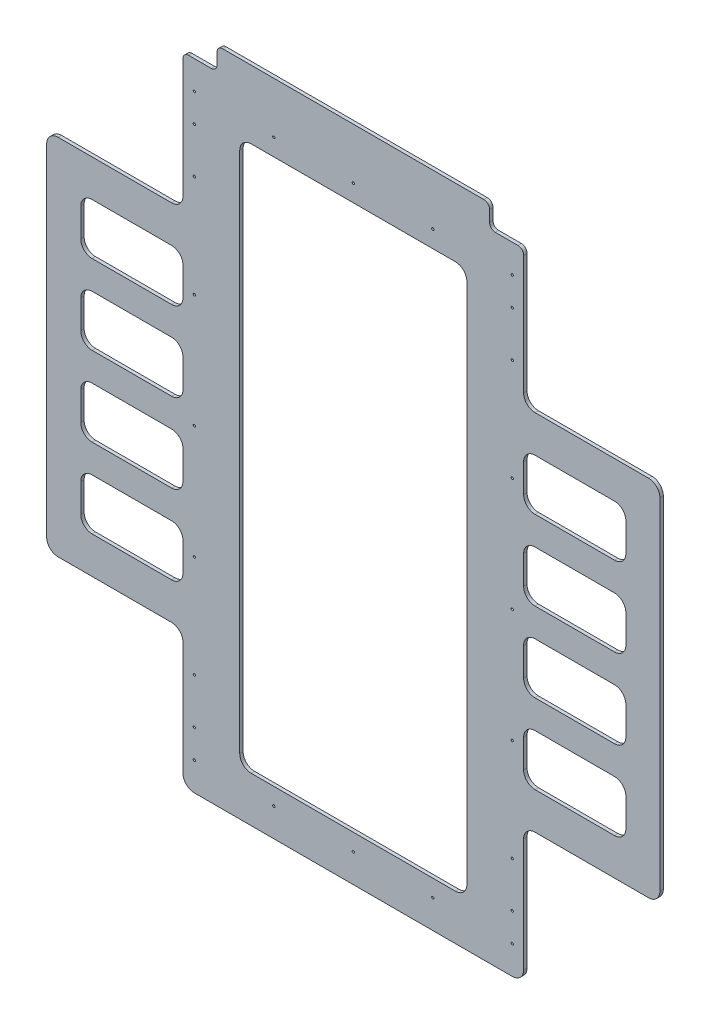
from build123d import *

# Parameters (mm, degrees)
EXTRUDE_1_DEPTH     = 3
SKETCH_2_R          = 1
CUT_EXTRUDE_1_DEPTH = 3


with BuildPart() as part:
    # 草图1 → 凸台-拉伸1 (new body)
    with BuildSketch(Plane.XY):
        with BuildLine():
            Line((-140, -280), (140, -280))
            ThreePointArc((140, -280), (147.071067812, -277.071067812), (150, -270))
            Line((150, -270), (150, -170))
            ThreePointArc((150, -170), (152.928932188, -162.928932188), (160, -160))
            Line((160, -160), (260, -160))
            ThreePointArc((260, -160), (267.071067812, -157.071067812), (270, -150))
            Line((270, -150), (270, 150))
            ThreePointArc((270, 150), (267.071067812, 157.071067812), (260, 160))
            Line((260, 160), (160, 160))
            ThreePointArc((160, 160), (152.928932188, 162.928932188), (150, 170))
            Line((150, 170), (150, 275))
            ThreePointArc((150, 275), (148.535533906, 278.535533906), (145, 280))
            Line((145, 280), (125, 280))
            ThreePointArc((125, 280), (121.464466094, 281.464466094), (120, 285))
            Line((120, 285), (120, 295))
            ThreePointArc((120, 295), (118.535533906, 298.535533906), (115, 300))
            Line((115, 300), (-115, 300))
            ThreePointArc((-115, 300), (-118.535533906, 298.535533906), (-120, 295))
            Line((-120, 295), (-120, 285))
            ThreePointArc((-120, 285), (-121.464466094, 281.464466094), (-125, 280))
            Line((-125, 280), (-145, 280))
            ThreePointArc((-145, 280), (-148.535533906, 278.535533906), (-150, 275))
            Line((-150, 275), (-150, 170))
            ThreePointArc((-150, 170), (-152.928932188, 162.928932188), (-160, 160))
            Line((-160, 160), (-260, 160))
            ThreePointArc((-260, 160), (-267.071067812, 157.071067812), (-270, 150))
            Line((-270, 150), (-270, -150))
            ThreePointArc((-270, -150), (-267.071067812, -157.071067812), (-260, -160))
            Line((-260, -160), (-160, -160))
            ThreePointArc((-160, -160), (-152.928932188, -162.928932188), (-150, -170))
            Line((-150, -170), (-150, -270))
            ThreePointArc((-150, -270), (-147.071067812, -277.071067812), (-140, -280))
        make_face()
        with BuildLine():
            Line((-90, 240), (90, 240))
            ThreePointArc((90, 240), (97.071067812, 237.071067812), (100, 230))
            Line((100, 230), (100, -230))
            ThreePointArc((100, -230), (97.071067812, -237.071067812), (90, -240))
            Line((90, -240), (-90, -240))
            ThreePointArc((-90, -240), (-97.071067812, -237.071067812), (-100, -230))
            Line((-100, -230), (-100, 230))
            ThreePointArc((-100, 230), (-97.071067812, 237.071067812), (-90, 240))
        make_face(mode=Mode.SUBTRACT)
        with BuildLine():
            Line((-240, 47.5), (-240, 22.5))
            ThreePointArc((-240, 22.5), (-237.071067812, 15.428932188), (-230, 12.5))
            Line((-230, 12.5), (-160, 12.5))
            ThreePointArc((-160, 12.5), (-152.928932188, 15.428932188), (-150, 22.5))
            Line((-150, 22.5), (-150, 47.5))
            ThreePointArc((-150, 47.5), (-152.928932188, 54.571067812), (-160, 57.5))
            Line((-160, 57.5), (-230, 57.5))
            ThreePointArc((-230, 57.5), (-237.071067812, 54.571067812), (-240, 47.5))
        make_face(mode=Mode.SUBTRACT)
        with BuildLine():
            Line((-230, 127.5), (-160, 127.5))
            ThreePointArc((-160, 127.5), (-152.928932188, 124.571067812), (-150, 117.5))
            Line((-150, 117.5), (-150, 92.5))
            ThreePointArc((-150, 92.5), (-152.928932188, 85.428932188), (-160, 82.5))
            Line((-160, 82.5), (-230, 82.5))
            ThreePointArc((-230, 82.5), (-237.071067812, 85.428932188), (-240, 92.5))
            Line((-240, 92.5), (-240, 117.5))
            ThreePointArc((-240, 117.5), (-237.071067812, 124.571067812), (-230, 127.5))
        make_face(mode=Mode.SUBTRACT)
        with BuildLine():
            Line((-240, -22.5), (-240, -47.5))
            ThreePointArc((-240, -47.5), (-237.071067812, -54.571067812), (-230, -57.5))
            Line((-230, -57.5), (-160, -57.5))
            ThreePointArc((-160, -57.5), (-152.928932188, -54.571067812), (-150, -47.5))
            Line((-150, -47.5), (-150, -22.5))
            ThreePointArc((-150, -22.5), (-152.928932188, -15.428932188), (-160, -12.5))
            Line((-160, -12.5), (-230, -12.5))
            ThreePointArc((-230, -12.5), (-237.071067812, -15.428932188), (-240, -22.5))
        make_face(mode=Mode.SUBTRACT)
        with BuildLine():
            Line((-240, -92.5), (-240, -117.5))
            ThreePointArc((-240, -117.5), (-237.071067812, -124.571067812), (-230, -127.5))
            Line((-230, -127.5), (-160, -127.5))
            ThreePointArc((-160, -127.5), (-152.928932188, -124.571067812), (-150, -117.5))
            Line((-150, -117.5), (-150, -92.5))
            ThreePointArc((-150, -92.5), (-152.928932188, -85.428932188), (-160, -82.5))
            Line((-160, -82.5), (-230, -82.5))
            ThreePointArc((-230, -82.5), (-237.071067812, -85.428932188), (-240, -92.5))
        make_face(mode=Mode.SUBTRACT)
        with BuildLine():
            Line((230, -127.5), (160, -127.5))
            ThreePointArc((160, -127.5), (152.928932188, -124.571067812), (150, -117.5))
            Line((150, -117.5), (150, -92.5))
            ThreePointArc((150, -92.5), (152.928932188, -85.428932188), (160, -82.5))
            Line((160, -82.5), (230, -82.5))
            ThreePointArc((230, -82.5), (237.071067812, -85.428932188), (240, -92.5))
            Line((240, -92.5), (240, -117.5))
            ThreePointArc((240, -117.5), (237.071067812, -124.571067812), (230, -127.5))
        make_face(mode=Mode.SUBTRACT)
        with BuildLine():
            Line((230, -57.5), (160, -57.5))
            ThreePointArc((160, -57.5), (152.928932188, -54.571067812), (150, -47.5))
            Line((150, -47.5), (150, -22.5))
            ThreePointArc((150, -22.5), (152.928932188, -15.428932188), (160, -12.5))
            Line((160, -12.5), (230, -12.5))
            ThreePointArc((230, -12.5), (237.071067812, -15.428932188), (240, -22.5))
            Line((240, -22.5), (240, -47.5))
            ThreePointArc((240, -47.5), (237.071067812, -54.571067812), (230, -57.5))
        make_face(mode=Mode.SUBTRACT)
        with BuildLine():
            Line((230, 12.5), (160, 12.5))
            ThreePointArc((160, 12.5), (152.928932188, 15.428932188), (150, 22.5))
            Line((150, 22.5), (150, 47.5))
            ThreePointArc((150, 47.5), (152.928932188, 54.571067812), (160, 57.5))
            Line((160, 57.5), (230, 57.5))
            ThreePointArc((230, 57.5), (237.071067812, 54.571067812), (240, 47.5))
            Line((240, 47.5), (240, 22.5))
            ThreePointArc((240, 22.5), (237.071067812, 15.428932188), (230, 12.5))
        make_face(mode=Mode.SUBTRACT)
        with BuildLine():
            Line((150, 117.5), (150, 92.5))
            ThreePointArc((150, 92.5), (152.928932188, 85.428932188), (160, 82.5))
            Line((160, 82.5), (230, 82.5))
            ThreePointArc((230, 82.5), (237.071067812, 85.428932188), (240, 92.5))
            Line((240, 92.5), (240, 117.5))
            ThreePointArc((240, 117.5), (237.071067812, 124.571067812), (230, 127.5))
            Line((230, 127.5), (160, 127.5))
            ThreePointArc((160, 127.5), (152.928932188, 124.571067812), (150, 117.5))
        make_face(mode=Mode.SUBTRACT)
    extrude(amount=EXTRUDE_1_DEPTH)

    # 草图2 → 切除-拉伸1 (cut)
    with BuildSketch(Plane.XY.offset(3)):
        with Locations((0, 255)):
            Circle(SKETCH_2_R)
        with Locations((70, 255)):
            Circle(SKETCH_2_R)
        with Locations((140, 255)):
            Circle(SKETCH_2_R)
        with Locations((-70, 255)):
            Circle(SKETCH_2_R)
        with Locations((-140, 255)):
            Circle(SKETCH_2_R)
        with Locations((-140, 0)):
            Circle(SKETCH_2_R)
        with Locations((-140, 100)):
            Circle(SKETCH_2_R)
        with Locations((-140, 190)):
            Circle(SKETCH_2_R)
        with Locations((-140, 230)):
            Circle(SKETCH_2_R)
        with Locations((-140, -230)):
            Circle(SKETCH_2_R)
        with Locations((-140, -190)):
            Circle(SKETCH_2_R)
        with Locations((-140, -100)):
            Circle(SKETCH_2_R)
        with Locations((-140, -255)):
            Circle(SKETCH_2_R)
        with Locations((-70, -255)):
            Circle(SKETCH_2_R)
        with Locations((140, -255)):
            Circle(SKETCH_2_R)
        with Locations((70, -255)):
            Circle(SKETCH_2_R)
        with Locations((0, -255)):
            Circle(SKETCH_2_R)
        with Locations((140, -100)):
            Circle(SKETCH_2_R)
        with Locations((140, -190)):
            Circle(SKETCH_2_R)
        with Locations((140, -230)):
            Circle(SKETCH_2_R)
        with Locations((140, 100)):
            Circle(SKETCH_2_R)
        with Locations((140, 0)):
            Circle(SKETCH_2_R)
        with Locations((140, 190)):
            Circle(SKETCH_2_R)
        with Locations((140, 230)):
            Circle(SKETCH_2_R)
    extrude(amount=-CUT_EXTRUDE_1_DEPTH, mode=Mode.SUBTRACT)


solid = part.part
